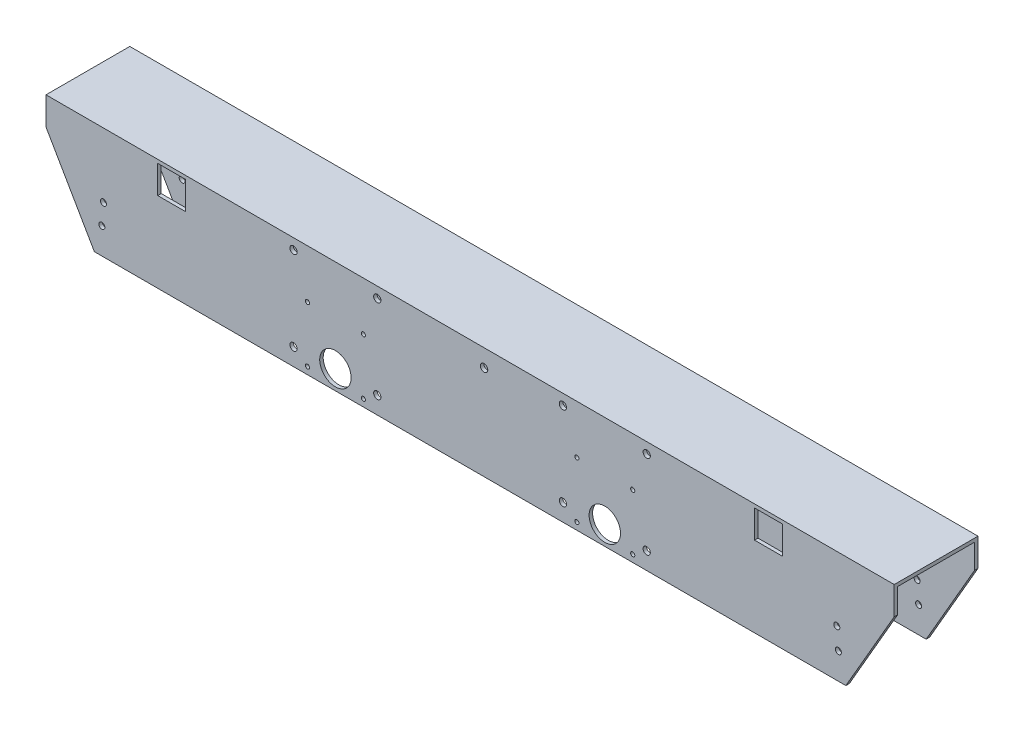
from build123d import *

# Parameters (mm, degrees)
BOSS_EXTRUDE1_DEPTH     = 385.705756272
SKETCH2_R               = 2.749999961
SKETCH2_R_2             = 14.2875
SKETCH2_R_3             = 2.75
CUT_EXTRUDE1_DEPTH      = 141.732
SKETCH14_R              = 3.302
CUT_EXTRUDE12_DEPTH     = 77.2
CUT_EXTRUDE13_DEPTH     = 101.6
SKETCH17_W              = 25.4
SKETCH17_H              = 25.4
CUT_EXTRUDE19_DEPTH     = 25.4
F_1_4_CLEARANCE_HOLE1_D = 6.7564
F_6_CLEARANCE_HOLE1_D   = 3.7973
CUT_EXTRUDE20_REACH     = 78.2
SKETCH25_W              = 25.4
SKETCH25_H              = 25.4
F_6_CLEARANCE_HOLE2_D   = 3.7973


with BuildPart() as part:
    # Sketch1 → Boss-Extrude1 (new body, symmetric)
    with BuildSketch(Plane(origin=(0, 0, 0), x_dir=(0, 0, -1), z_dir=(1, 0, 0))):
        Polygon((-38.1, 50.8), (38.1, 50.8), (38.1, -50.8), (34.925, -50.8), (34.925, 47.625), (-34.925, 47.625), (-34.925, -50.8), (-38.1, -50.8), align=None)
    extrude(amount=BOSS_EXTRUDE1_DEPTH, both=True)

    # Sketch2 → Cut-Extrude1 (cut)
    with BuildSketch(Plane.XY.offset(38.1)):
        with Locations((-333.475837626, -7.9375)):
            Circle(SKETCH2_R)
        with Locations((122.50039, -33.3375)):
            Circle(SKETCH2_R_2)
        with Locations((333.475837626, -7.9375)):
            Circle(SKETCH2_R)
        with Locations((334.902632555, -26.927596819)):
            Circle(SKETCH2_R_3)
        with Locations((-122.50039, -33.3375)):
            Circle(SKETCH2_R_2)
        with Locations((-334.902632555, -26.927596819)):
            Circle(SKETCH2_R_3)
    extrude(amount=-CUT_EXTRUDE1_DEPTH, mode=Mode.SUBTRACT)

    # Sketch14 → Cut-Extrude12 (cut, through all)
    with BuildSketch(Plane(origin=(0, 0, -38.1), x_dir=(-1, 0, 0), z_dir=(0, 0, -1))):
        with Locations((-160.60039, -35.123476108)):
            Circle(SKETCH14_R)
        with Locations((-160.61182, 41.076523035)):
            Circle(SKETCH14_R)
        with Locations((-84.41182, 41.076523892)):
            Circle(SKETCH14_R)
        with Locations((-84.41182, -35.123476108)):
            Circle(SKETCH14_R)
        with Locations((160.60039, -35.123476108)):
            Circle(SKETCH14_R)
        with Locations((84.41182, -35.123476108)):
            Circle(SKETCH14_R)
        with Locations((84.41182, 41.076523892)):
            Circle(SKETCH14_R)
        with Locations((160.61182, 41.076523035)):
            Circle(SKETCH14_R)
    extrude(amount=-CUT_EXTRUDE12_DEPTH, mode=Mode.SUBTRACT)

    # Sketch16 → Cut-Extrude13 (cut)
    with BuildSketch(Plane.XY.offset(38.1)):
        Polygon((-385.705756272, 25.4), (-341.71166576, -50.8), (-385.705756272, -50.8), align=None)
        Polygon((341.71166576, -50.8), (385.705756272, -50.8), (385.705756272, 25.4), align=None)
    extrude(amount=-CUT_EXTRUDE13_DEPTH, mode=Mode.SUBTRACT)

    # Sketch17 → Cut-Extrude19 (cut)
    with BuildSketch(Plane(origin=(0, 0, -38.1), x_dir=(-1, 0, 0), z_dir=(0, 0, -1))):
        with Locations((-12.7, 34.925)):
            Rectangle(SKETCH17_W, SKETCH17_H)
        with Locations((273.24, 34.925)):
            Rectangle(SKETCH17_W, SKETCH17_H)
    extrude(amount=-CUT_EXTRUDE19_DEPTH, mode=Mode.SUBTRACT)

    # 1/4 Clearance Hole1 (through all)
    with Locations(Plane(origin=(0, 0, -38.1), x_dir=(-1, 0, 0), z_dir=(0, 0, -1))):
        with Locations((-12.7, 34.925), (273.24, 34.925)):
            Hole(F_1_4_CLEARANCE_HOLE1_D / 2)

    # #6 Clearance Hole1 (through all)
    with Locations(Plane.XY.offset(38.1)):
        with Locations((-147.90039, -44.3), (-97.10039, -44.3), (97.10039, -44.3), (147.90039, -44.3), (-147.90039, 6.5), (-97.10039, 6.5), (97.10039, 6.5), (147.90039, 6.5)):
            Hole(F_6_CLEARANCE_HOLE1_D / 2)

    # Sketch25 → Cut-Extrude20 (cut, up to next)
    with BuildSketch(Plane.XY.offset(38.1), mode=Mode.PRIVATE) as cut_extrude20_sk1:
        with Locations((271.405756272, 34.925)):
            Rectangle(SKETCH25_W, SKETCH25_H)
    cut_extrude20_tool1 = extrude(cut_extrude20_sk1.sketch, amount=-CUT_EXTRUDE20_REACH, mode=Mode.PRIVATE) & part.part
    add(cut_extrude20_tool1.solids().sort_by_distance((271.405756, 34.925, 38.1))[0], mode=Mode.SUBTRACT)
    # Sketch25 → Cut-Extrude20 (cut, up to next)
    with BuildSketch(Plane.XY.offset(38.1), mode=Mode.PRIVATE) as cut_extrude20_sk2:
        with Locations((-271.405756272, 34.925)):
            Rectangle(SKETCH25_W, SKETCH25_H)
    cut_extrude20_tool2 = extrude(cut_extrude20_sk2.sketch, amount=-CUT_EXTRUDE20_REACH, mode=Mode.PRIVATE) & part.part
    add(cut_extrude20_tool2.solids().sort_by_distance((-271.405756, 34.925, 38.1))[0], mode=Mode.SUBTRACT)

    # #6 Clearance Hole2 (through all)
    with Locations(Plane.XY.offset(-34.925)):
        with Locations((-271.405756272, 34.925), (271.405756272, 34.925)):
            Hole(F_6_CLEARANCE_HOLE2_D / 2)


solid = part.part
